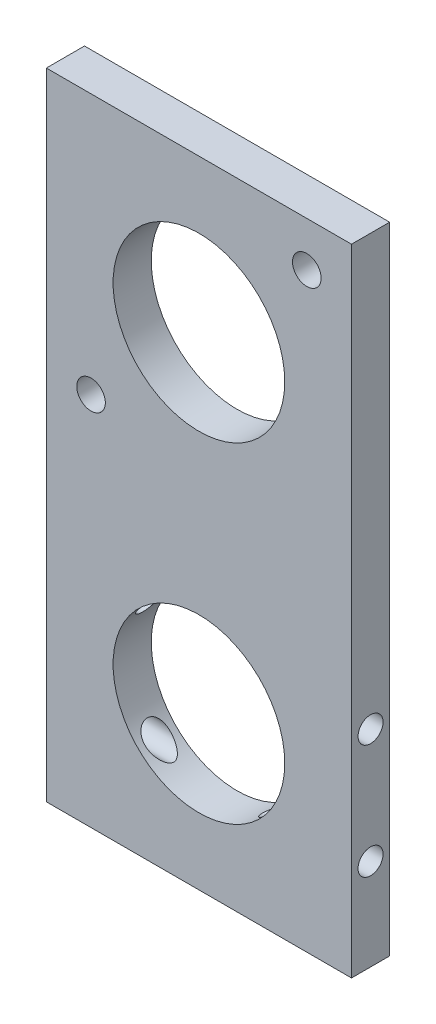
from build123d import *

# Parameters (mm, degrees)
SKETCH2_W           = 50.8
SKETCH2_H           = 105.799998966
SKETCH2_R           = 14.2875
SKETCH2_R_2         = 2.38125
BOSS_EXTRUDE1_DEPTH = 6.35
SKETCH6_R           = 2.0828
CUT_EXTRUDE1_DEPTH  = 51.8


with BuildPart() as part:
    # Sketch2 → Boss-Extrude1 (new body)
    with BuildSketch(Plane.XY):
        with Locations((0, -27.499999483)):
            Rectangle(SKETCH2_W, SKETCH2_H)
        Circle(SKETCH2_R, mode=Mode.SUBTRACT)
        with Locations((0, -54.999998966)):
            Circle(SKETCH2_R, mode=Mode.SUBTRACT)
        with Locations((-17.960512242, -17.960512242)):
            Circle(SKETCH2_R_2, mode=Mode.SUBTRACT)
        with Locations((17.960512242, 17.960512242)):
            Circle(SKETCH2_R_2, mode=Mode.SUBTRACT)
    extrude(amount=BOSS_EXTRUDE1_DEPTH)

    # Sketch6 → Cut-Extrude1 (cut, through all)
    with BuildSketch(Plane(origin=(25.4, 0, 0), x_dir=(0, 0, -1), z_dir=(1, 0, 0))):
        with Locations((-3.175, -65.159998966)):
            Circle(SKETCH6_R)
        with Locations((-3.175, -46.109998966)):
            Circle(SKETCH6_R)
    extrude(amount=-CUT_EXTRUDE1_DEPTH, mode=Mode.SUBTRACT)


solid = part.part
